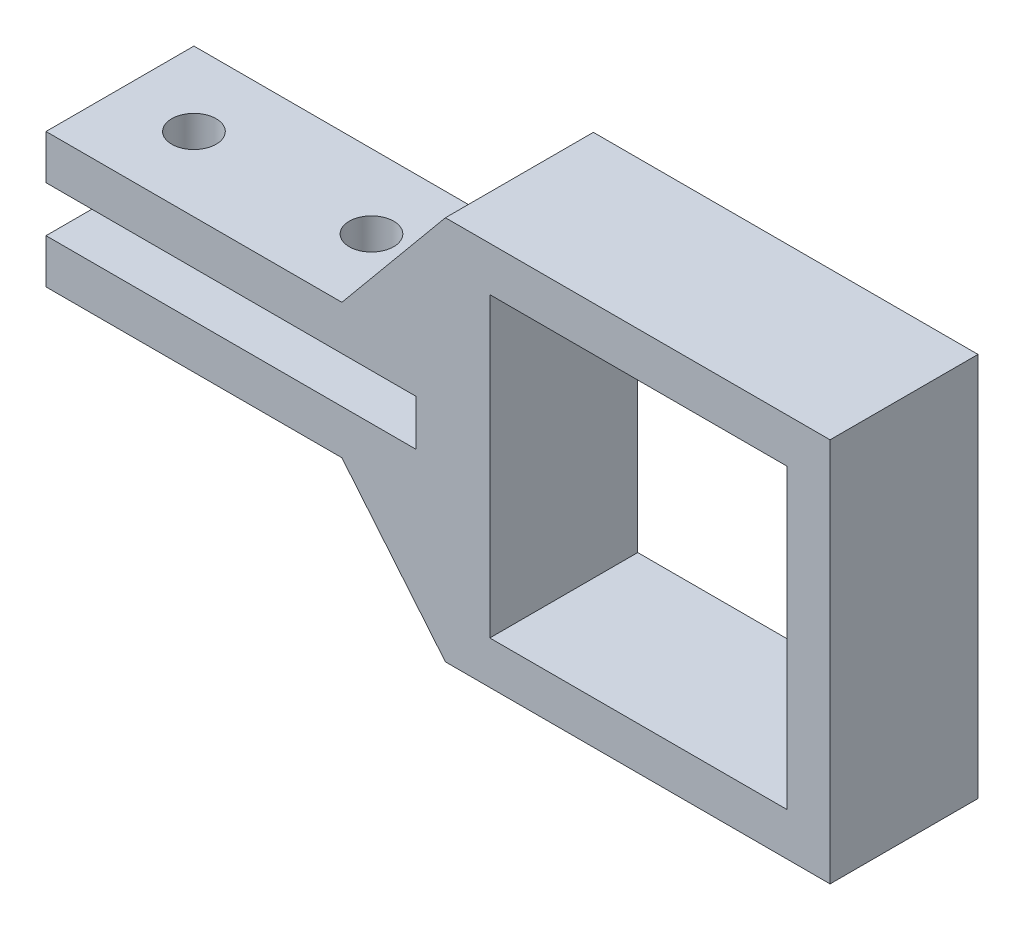
from build123d import *

# Parameters (mm, degrees)
EXTRUDE_1_DEPTH     = 10
SKETCH_5_W          = 20.1
SKETCH_5_H          = 20.1
CUT_EXTRUDE_1_DEPTH = 30
SKETCH_7_R          = 1.5
CUT_EXTRUDE_5_DEPTH = 9.1


with BuildPart() as part:
    # 草图1 → 凸台-拉伸1 (new body)
    with BuildSketch(Plane.XY):
        Polygon((-27, 4.55), (-27, 1.55), (-2, 1.55), (-2, -1.55), (-27, -1.55), (-27, -4.55), (-7, -4.55), (0, -13), (26, -13), (26, 13), (0, 13), (-7, 4.55), align=None)
    extrude(amount=EXTRUDE_1_DEPTH)

    # 草图5 → 切除-拉伸1 (cut)
    with BuildSketch(Plane.XY.offset(10)):
        with Locations((13.05, -0.05)):
            Rectangle(SKETCH_5_W, SKETCH_5_H)
    extrude(amount=-CUT_EXTRUDE_1_DEPTH, mode=Mode.SUBTRACT)

    # 草图7 → 切除-拉伸5 (cut)
    with BuildSketch(Plane(origin=(0, 4.55, 0), x_dir=(1, 0, 0), z_dir=(0, 1, 0))):
        with Locations((-22, -5)):
            Circle(SKETCH_7_R)
        with Locations((-10, -5)):
            Circle(SKETCH_7_R)
    extrude(amount=-CUT_EXTRUDE_5_DEPTH, mode=Mode.SUBTRACT)


solid = part.part
